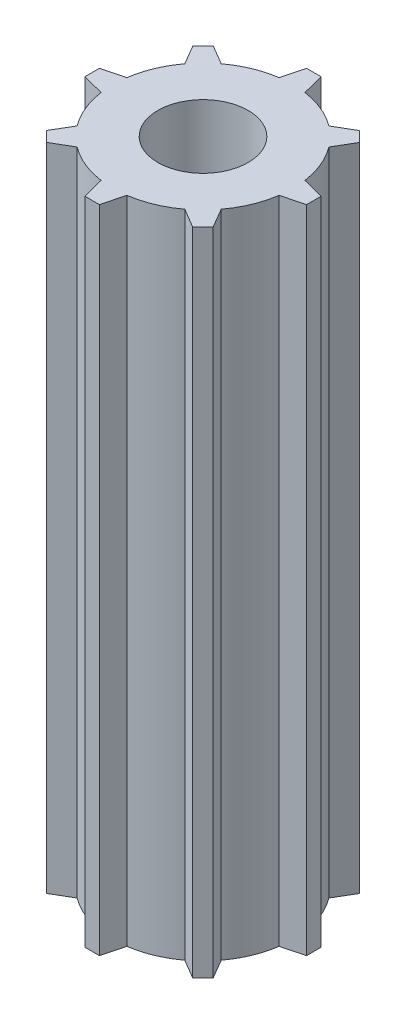
from build123d import *

# Parameters (mm, degrees)
BOSS_EXTRUDE4_DEPTH = 45.72
SKETCH9_R           = 3.175
CUT_EXTRUDE3_DEPTH  = 30.48


with BuildPart() as part:
    # Sketch8 → Boss-Extrude4 (new body)
    with BuildSketch(Plane(origin=(0, 0, 0), x_dir=(1, 0, 0), z_dir=(0, 1, 0))):
        with BuildLine():
            Line((-0.905835842, 6.259395066), (-0.505053709, 7.788795718))
            Line((-0.505053709, 7.788795718), (0.510946291, 7.788795718))
            Line((0.510946291, 7.788795718), (0.905835842, 6.259395066))
            ThreePointArc((0.905835842, 6.259395066), (2.420319636, 5.843168491), (3.785538031, 5.066583363))
            Line((3.785538031, 5.066583363), (5.150383367, 5.864637172))
            Line((5.150383367, 5.864637172), (5.868803857, 5.146216682))
            Line((5.868803857, 5.146216682), (5.066583363, 3.785538031))
            ThreePointArc((5.066583363, 3.785538031), (5.843168491, 2.420319636), (6.259395066, 0.905835842))
            Line((6.259395066, 0.905835842), (7.788795718, 0.505053709))
            Line((7.788795718, 0.505053709), (7.788795718, -0.510946291))
            Line((7.788795718, -0.510946291), (6.259395066, -0.905835842))
            ThreePointArc((6.259395066, -0.905835842), (5.843168491, -2.420319636), (5.066583363, -3.785538031))
            Line((5.066583363, -3.785538031), (5.864637172, -5.150383367))
            Line((5.864637172, -5.150383367), (5.146216682, -5.868803857))
            Line((5.146216682, -5.868803857), (3.785538031, -5.066583363))
            ThreePointArc((3.785538031, -5.066583363), (2.420319636, -5.843168491), (0.905835842, -6.259395066))
            Line((0.905835842, -6.259395066), (0.505053709, -7.788795718))
            Line((0.505053709, -7.788795718), (-0.510946291, -7.788795718))
            Line((-0.510946291, -7.788795718), (-0.905835842, -6.259395066))
            ThreePointArc((-0.905835842, -6.259395066), (-2.420319636, -5.843168491), (-3.785538031, -5.066583363))
            Line((-3.785538031, -5.066583363), (-5.150383367, -5.864637172))
            Line((-5.150383367, -5.864637172), (-5.868803857, -5.146216682))
            Line((-5.868803857, -5.146216682), (-5.066583363, -3.785538031))
            ThreePointArc((-5.066583363, -3.785538031), (-5.843168491, -2.420319636), (-6.259395066, -0.905835842))
            Line((-6.259395066, -0.905835842), (-7.788795718, -0.505053709))
            Line((-7.788795718, -0.505053709), (-7.788795718, 0.510946291))
            Line((-7.788795718, 0.510946291), (-6.259395066, 0.905835842))
            ThreePointArc((-6.259395066, 0.905835842), (-5.843168491, 2.420319636), (-5.066583363, 3.785538031))
            Line((-5.066583363, 3.785538031), (-5.864637172, 5.150383367))
            Line((-5.864637172, 5.150383367), (-5.146216682, 5.868803857))
            Line((-5.146216682, 5.868803857), (-3.785538031, 5.066583363))
            ThreePointArc((-3.785538031, 5.066583363), (-2.420319636, 5.843168491), (-0.905835842, 6.259395066))
        make_face()
    extrude(amount=BOSS_EXTRUDE4_DEPTH)

    # Sketch9 → Cut-Extrude3 (cut)
    with BuildSketch(Plane(origin=(0, 45.72, 0), x_dir=(1, 0, 0), z_dir=(0, 1, 0))):
        Circle(SKETCH9_R)
    extrude(amount=-CUT_EXTRUDE3_DEPTH, mode=Mode.SUBTRACT)


solid = part.part
